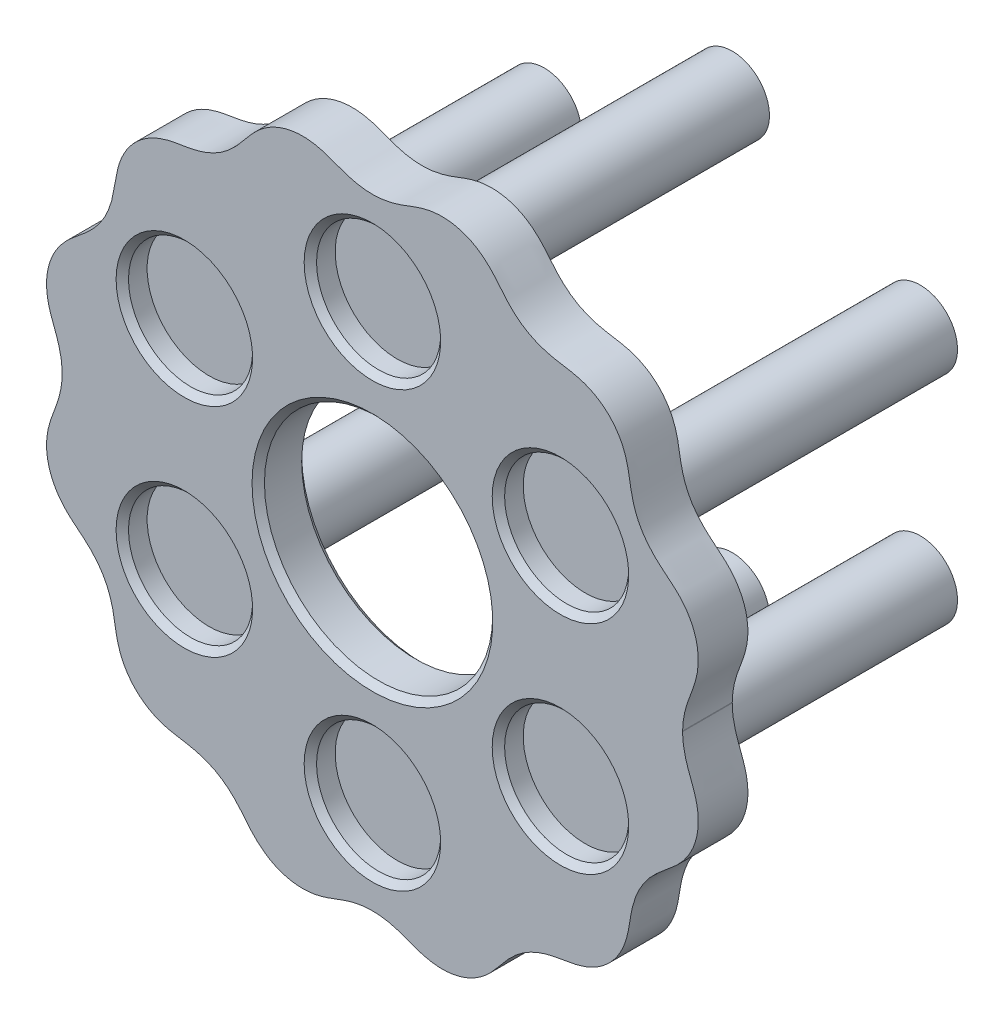
from build123d import *

# Parameters (mm, degrees)
SKETCH3_R           = 9.2
BOSS_EXTRUDE2_DEPTH = 4
SKETCH7_R           = 3
BOSS_EXTRUDE3_DEPTH = 25
SKETCH6_R           = 5
CUT_EXTRUDE2_DEPTH  = 2
FILLET1_R           = 1
CHAMFER1_SIZE       = 0.5


with BuildPart() as part:
    # Sketch3 → Boss-Extrude2 (new body)
    with BuildSketch(Plane.XY):
        with BuildLine():
            add(Edge.make_bspline(
                [(25, 0), (25, -0.028419379), (25.000492821, -0.085240091), (25.002710517, -0.186096381), (25.008616202, -0.331732724), (25.017454216, -0.471095426), (25.029199756, -0.604110594), (25.043819456, -0.735775062), (25.0612711, -0.868216065), (25.086561311, -1.034185241), (25.122348392, -1.232409452), (25.171720804, -1.461619521), (25.23785416, -1.72161835), (25.33146082, -2.043525868), (25.437671669, -2.361532194), (25.552791346, -2.676356937), (25.69530689, -3.052450734), (25.837320412, -3.428807717), (26.007461604, -3.919608843), (26.169082038, -4.536352918), (26.29301302, -5.400577617), (26.248865742, -6.509268079), (25.900590468, -7.758927573), (25.250933039, -8.824024045), (24.559448754, -9.548775191), (23.872924134, -10.132867754), (23.242034799, -10.633504856), (22.540451444, -11.262027255), (21.859772382, -12.093532725), (21.337087227, -13.027141562), (20.986474338, -14.032216693), (20.783152218, -15.069054613), (20.629229677, -16.210615672), (20.295790024, -17.423577203), (19.620081418, -18.614367157), (18.57817853, -19.648167397), (17.377311503, -20.316253266), (16.151486918, -20.639994045), (14.739949908, -20.826544524), (13.439402762, -21.1258531), (12.23711891, -21.731124361), (11.217263285, -22.586282659), (10.510510486, -23.382376891), (9.803864636, -24.301158332), (8.912502074, -25.202295013), (7.731407454, -25.911659846), (6.309337856, -26.299864083), (4.931582798, -26.288472232), (3.706115601, -25.964583322), (2.633674004, -25.522967435), (1.62667227, -25.181750578), (0.581426656, -24.989102643), (-0.478930933, -24.980713481), (-1.520966388, -25.154635937), (-2.520449471, -25.479461333), (-3.419229104, -25.84785235), (-4.274357012, -26.11935553), (-5.084141891, -26.255225085), (-5.827195666, -26.277840049), (-6.751118437, -26.176673588), (-7.819413481, -25.850368791), (-8.864535557, -25.241992085), (-9.774472842, -24.337578456), (-10.489042176, -23.409443312), (-11.198070814, -22.604475083), (-12.019349647, -21.910802096), (-12.950687048, -21.371323607), (-13.961150534, -21.004447957), (-15.012542859, -20.790681073), (-16.17349347, -20.636604415), (-17.412795128, -20.30409628), (-18.621589199, -19.617234196), (-19.535225069, -18.69087907), (-20.109505434, -17.744490957), (-20.468260184, -16.811352879), (-20.669325741, -15.929542243), (-20.800368009, -14.951283195), (-21.021499046, -13.897450049), (-21.399469544, -12.891789727), (-21.945671579, -11.971536034), (-22.639598338, -11.164500934), (-23.435367487, -10.469229858), (-24.347111984, -9.765350187), (-25.232158972, -8.871517572), (-25.925709908, -7.694669196), (-26.301679816, -6.282910402), (-26.285367064, -4.916976266), (-25.96232166, -3.701401982), (-25.524214021, -2.636206013), (-25.184526072, -1.63546138), (-24.98964456, -0.589100982), (-24.979676648, 0.481005828), (-25.157831343, 1.540454587), (-25.495205931, 2.562927815), (-25.870736407, 3.4757204), (-26.135455064, 4.34059116), (-26.288515222, 5.328583568), (-26.261093111, 6.43001327), (-25.933564455, 7.678441647), (-25.237701394, 8.866637346), (-24.34504384, 9.767557339), (-23.427022399, 10.47557852), (-22.62699323, 11.1763696), (-21.936896568, 11.984292454), (-21.397747575, 12.897748952), (-21.026718925, 13.886522177), (-20.806135146, 14.914602211), (-20.653045268, 16.060286336), (-20.395622874, 17.11611043), (-19.95690194, 18.028441349), (-19.300149626, 18.928757994), (-18.483671803, 19.692277913), (-17.435839429, 20.294614033), (-16.197622229, 20.632400397), (-15.036829757, 20.787344769), (-13.984887122, 20.997904882), (-12.973147938, 21.361026229), (-12.039474616, 21.896555136), (-11.215678135, 22.58716662), (-10.504008287, 23.390162439), (-9.790282182, 24.318640694), (-8.884052218, 25.226941722), (-7.685868846, 25.932204762), (-6.427337904, 26.262197332), (-5.32062142, 26.288060185), (-4.332905845, 26.133623194), (-3.468339345, 25.867884001), (-2.55560208, 25.492296977), (-1.532755887, 25.155882506), (-0.473083435, 24.979033961), (0.597006536, 24.990441303), (1.643127458, 25.186582226), (2.643510183, 25.527172752), (3.708827205, 25.965063812), (4.924909383, 26.286396603), (6.29085556, 26.300692327), (7.702048601, 25.922603812), (8.877880267, 25.227310889), (9.770417048, 24.341030317), (10.474070774, 23.429151565), (11.170105737, 22.633979321), (11.977973527, 21.941022037), (12.898969216, 21.396054985), (13.905080963, 21.019330701), (14.959093015, 20.79921578), (15.93734026, 20.668117182), (16.818953838, 20.466007301), (17.751576334, 20.105941467), (18.697120313, 19.53023506), (19.622089623, 18.615234931), (20.307180817, 17.405403853), (20.637904711, 16.165690953), (20.791787115, 15.004742729), (21.00656033, 13.953487), (21.374668771, 12.943487437), (21.915401419, 12.012841988), (22.610070929, 11.192473379), (23.415648604, 10.48411951), (24.343684699, 9.769551905), (25.246796647, 8.857951736), (25.940942688, 7.662077141), (26.262511444, 6.413848041), (26.28479299, 5.412288327), (26.191439435, 4.704296235), (26.088108997, 4.226630913), (25.967232391, 3.802316147), (25.80790495, 3.345695262), (25.619629464, 2.855327013), (25.458833672, 2.424502992), (25.333860765, 2.050706314), (25.241721849, 1.735435761), (25.176361339, 1.480873774), (25.120257899, 1.224415288), (25.074119122, 0.965148365), (25.038505918, 0.70465122), (25.016960864, 0.482504301), (25.005267885, 0.264321243), (25.00135895, 0.133217809), (25.000430803, 0.077544036), (25.000203175, 0.049701947)],
                knots=[0.076056741, 0.076056741, 0.076056741, 0.076056741, 0.076056741, 0.076716626, 0.077376511, 0.078036395, 0.07869628, 0.079356165, 0.080016049, 0.080675934, 0.081335819, 0.082655588, 0.083975357, 0.085295127, 0.086614896, 0.089254435, 0.090574204, 0.091893973, 0.094533512, 0.097173051, 0.100798473, 0.104423896, 0.11167474, 0.118848356, 0.126021971, 0.128665019, 0.131308067, 0.136594162, 0.141880258, 0.147166354, 0.152357566, 0.157548778, 0.16273999, 0.167931202, 0.175042017, 0.182152833, 0.189326507, 0.196500181, 0.201723091, 0.206946, 0.217391818, 0.222614771, 0.227837725, 0.233060678, 0.238283631, 0.245457287, 0.252630943, 0.259804707, 0.266978471, 0.272201179, 0.277423888, 0.282646597, 0.287869306, 0.293029544, 0.298189783, 0.303350022, 0.308510261, 0.312159961, 0.315809662, 0.319459363, 0.323109064, 0.330383447, 0.337657831, 0.342925117, 0.348192403, 0.353459689, 0.358726976, 0.363994339, 0.369261702, 0.374529065, 0.379796429, 0.387070764, 0.394345099, 0.401518721, 0.405105533, 0.408692344, 0.413978427, 0.419264509, 0.424550592, 0.429836675, 0.435027902, 0.440219129, 0.445410356, 0.450601583, 0.457712386, 0.464823188, 0.471933966, 0.479044743, 0.484236012, 0.489427281, 0.49461855, 0.499809819, 0.505095864, 0.510381909, 0.515667954, 0.520953999, 0.524540818, 0.528127637, 0.535301275, 0.542475056, 0.549648837, 0.554871514, 0.56009419, 0.565316866, 0.570539542, 0.575699809, 0.580860077, 0.586020345, 0.591180612, 0.598480006, 0.602129703, 0.605779399, 0.613053806, 0.620328213, 0.625595461, 0.630862709, 0.636129958, 0.641397206, 0.646664608, 0.651932009, 0.65719941, 0.662466812, 0.669741122, 0.677015431, 0.684189061, 0.687775877, 0.691362692, 0.696648757, 0.701934822, 0.707220888, 0.712506953, 0.7176982, 0.722889446, 0.728080693, 0.73327194, 0.740382729, 0.747493519, 0.754604309, 0.761715099, 0.766906345, 0.772097591, 0.777288837, 0.782480083, 0.787766149, 0.793052215, 0.798338281, 0.803624347, 0.807211162, 0.810797977, 0.817971607, 0.825245917, 0.832520228, 0.837787628, 0.843055028, 0.848322428, 0.853589828, 0.858857078, 0.864124328, 0.869391577, 0.874658827, 0.881933233, 0.889207639, 0.896231602, 0.899743584, 0.901499575, 0.903255566, 0.905841573, 0.908427581, 0.911013588, 0.913599595, 0.914892599, 0.916185603, 0.917478607, 0.91877161, 0.920064614, 0.921357618, 0.922650621, 0.923297123, 0.923943625, 0.923943625, 0.923943625, 0.923943625, 0.923943625], degree=4))
            Line((25.000203175, 0.049701947), (25, 0))
        make_face()
        Circle(SKETCH3_R, mode=Mode.SUBTRACT)
    extrude(amount=BOSS_EXTRUDE2_DEPTH)

    # Sketch7 → Boss-Extrude3 (add)
    with BuildSketch(Plane(origin=(0, 0, 0), x_dir=(-1, 0, 0), z_dir=(0, 0, -1))):
        with Locations((0, 17.5)):
            Circle(SKETCH7_R)
        with Locations((15.155444566, 8.75)):
            Circle(SKETCH7_R)
        with Locations((15.155444566, -8.75)):
            Circle(SKETCH7_R)
        with Locations((0, -17.5)):
            Circle(SKETCH7_R)
        with Locations((-15.155444566, -8.75)):
            Circle(SKETCH7_R)
        with Locations((-15.155444566, 8.75)):
            Circle(SKETCH7_R)
    extrude(amount=BOSS_EXTRUDE3_DEPTH)

    # Sketch6 → Cut-Extrude2 (cut)
    with BuildSketch(Plane.XY.offset(4)):
        with Locations((15.155444566, -8.75)):
            Circle(SKETCH6_R)
        with Locations((0, -17.5)):
            Circle(SKETCH6_R)
        with Locations((-15.155444566, -8.75)):
            Circle(SKETCH6_R)
        with Locations((15.155444566, 8.75)):
            Circle(SKETCH6_R)
        with Locations((0, 17.5)):
            Circle(SKETCH6_R)
        with Locations((-15.155444566, 8.75)):
            Circle(SKETCH6_R)
    extrude(amount=-CUT_EXTRUDE2_DEPTH, mode=Mode.SUBTRACT)

    # Fillet1
    fillet1_edges = [part.edges().sort_by_distance(p)[0] for p in [
        (-12.155444566, -8.75, 0),
        (3, 17.5, 0),
        (18.155444566, 8.75, 0),
        (18.155444566, -8.75, 0),
        (3, -17.5, 0),
        (-12.155444566, 8.75, 0),
    ]]
    fillet(fillet1_edges, radius=FILLET1_R)

    # Chamfer1
    chamfer1_edges = [part.edges().sort_by_distance(p)[0] for p in [
        (-5, -17.5, 4),
        (-20.155444566, -8.75, 4),
        (10.155444566, 8.75, 4),
        (-5, 17.5, 4),
        (-20.155444566, 8.75, 4),
        (10.155444566, -8.75, 4),
        (-9.2, 0, 0),
        (-9.2, 0, 4),
    ]]
    chamfer(chamfer1_edges, length=CHAMFER1_SIZE)


solid = part.part
